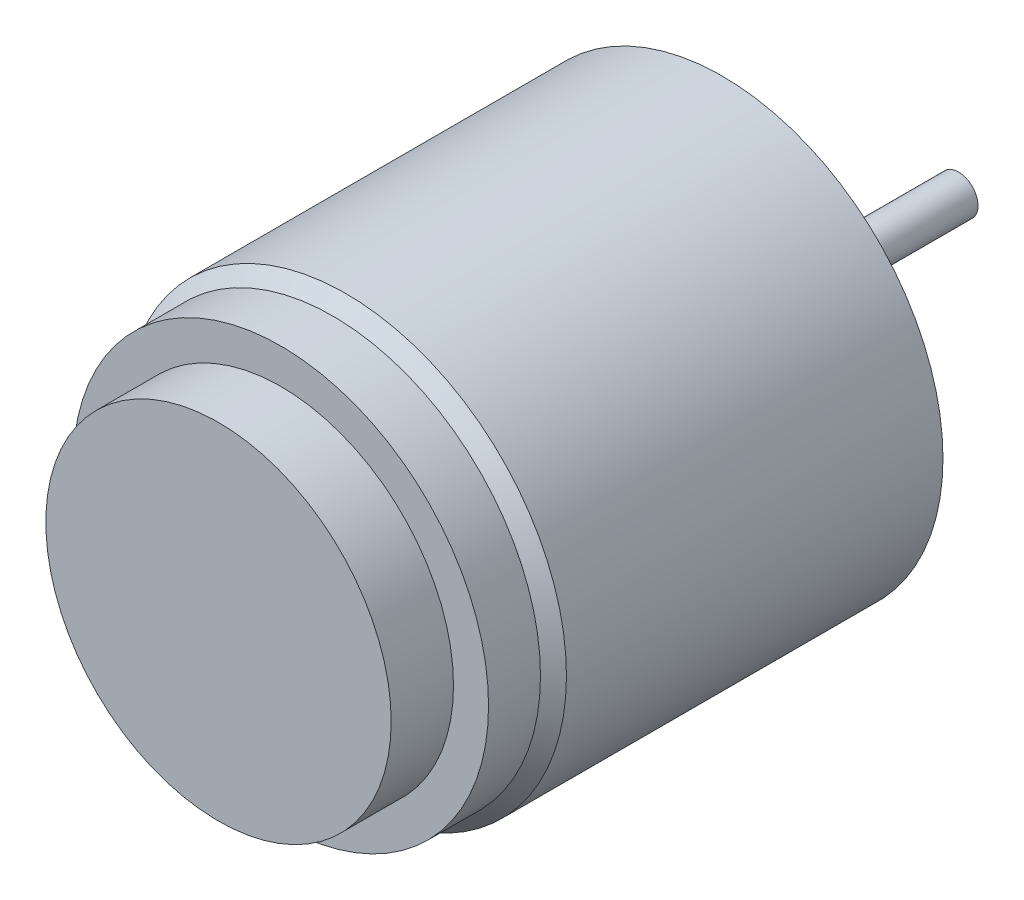
from build123d import *

# Parameters (mm, degrees)
SKETCH2_R           = 8.5
BOSS_EXTRUDE1_DEPTH = 15
CHAMFER1_SIZE       = 0.5
SKETCH3_R           = 8
BOSS_EXTRUDE2_DEPTH = 2
SKETCH4_R           = 6.65
BOSS_EXTRUDE3_DEPTH = 2.4
SKETCH5_R           = 0.8
CUT_EXTRUDE1_DEPTH  = 1.6
SKETCH6_R           = 3
BOSS_EXTRUDE4_DEPTH = 1
SKETCH7_R           = 1.75
BOSS_EXTRUDE5_DEPTH = 2.1
SKETCH8_R           = 0.75
BOSS_EXTRUDE6_DEPTH = 6


with BuildPart() as part:
    # Sketch2 → Boss-Extrude1 (new body)
    with BuildSketch(Plane.XY):
        Circle(SKETCH2_R)
    extrude(amount=BOSS_EXTRUDE1_DEPTH)

    # Chamfer1
    chamfer1_edges = [part.edges().sort_by_distance(p)[0] for p in [
        (-8.5, 0, 15),
    ]]
    chamfer(chamfer1_edges, length=CHAMFER1_SIZE)

    # Sketch3 → Boss-Extrude2 (add)
    with BuildSketch(Plane.XY.offset(15)):
        Circle(SKETCH3_R)
    extrude(amount=BOSS_EXTRUDE2_DEPTH)

    # Sketch4 → Boss-Extrude3 (add)
    with BuildSketch(Plane.XY.offset(17)):
        Circle(SKETCH4_R)
    extrude(amount=BOSS_EXTRUDE3_DEPTH)

    # Sketch5 → Cut-Extrude1 (cut)
    with BuildSketch(Plane(origin=(0, 0, 0), x_dir=(-1, 0, 0), z_dir=(0, 0, -1))):
        with Locations((0, 5)):
            Circle(SKETCH5_R)
        with Locations((4.330127019, 2.5)):
            Circle(SKETCH5_R)
        with Locations((4.330127019, -2.5)):
            Circle(SKETCH5_R)
        with Locations((0, -5)):
            Circle(SKETCH5_R)
        with Locations((-4.330127019, -2.5)):
            Circle(SKETCH5_R)
        with Locations((-4.330127019, 2.5)):
            Circle(SKETCH5_R)
    extrude(amount=-CUT_EXTRUDE1_DEPTH, mode=Mode.SUBTRACT)

    # Sketch6 → Boss-Extrude4 (add)
    with BuildSketch(Plane(origin=(0, 0, 0), x_dir=(-1, 0, 0), z_dir=(0, 0, -1))):
        Circle(SKETCH6_R)
    extrude(amount=BOSS_EXTRUDE4_DEPTH)

    # Sketch7 → Boss-Extrude5 (add)
    with BuildSketch(Plane(origin=(0, 0, -1), x_dir=(-1, 0, 0), z_dir=(0, 0, -1))):
        Circle(SKETCH7_R)
    extrude(amount=BOSS_EXTRUDE5_DEPTH)

    # Sketch8 → Boss-Extrude6 (add)
    with BuildSketch(Plane(origin=(0, 0, -3.1), x_dir=(-1, 0, 0), z_dir=(0, 0, -1))):
        Circle(SKETCH8_R)
    extrude(amount=BOSS_EXTRUDE6_DEPTH)


solid = part.part
